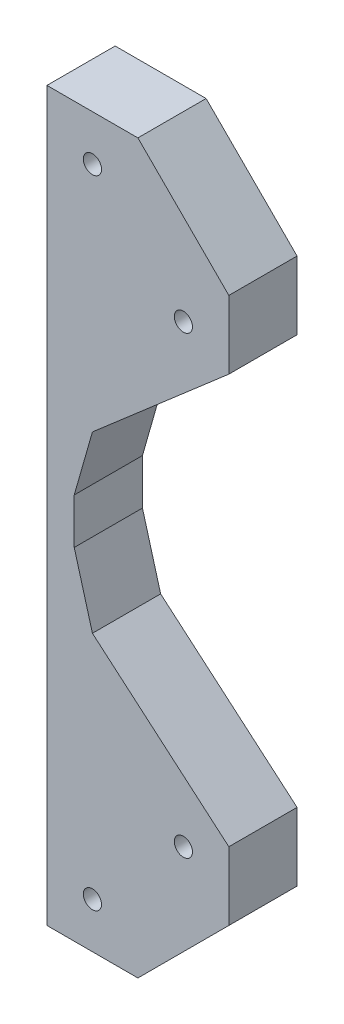
from build123d import *

# Parameters (mm, degrees)
ESBO_O1_R                = 2.000000328
ESBO_O1_R_2              = 1.999996603
ESBO_O1_R_3              = 1.999999862
RESSALTO_EXTRUS_O1_DEPTH = 15


with BuildPart() as part:
    # Esboço1 → Ressalto-extrusão1 (new body)
    with BuildSketch(Plane.XY):
        Polygon((0, 85.075276285), (19.999999553, 85.075276285), (39.999999106, 65.075280458), (39.999999106, 50.075279862), (9.999999776, 24.075279325), (6.000000052, 10.075005084), (6.000000052, 0.07499972), (9.999999776, -14.272091597), (39.999999106, -39.925275058), (39.999999106, -54.924720585), (19.999999553, -74.924720138), (0, -74.924720138), align=None)
        with Locations((9.999999776, 75.075278372)):
            Circle(ESBO_O1_R, mode=Mode.SUBTRACT)
        with Locations((29.999999329, 55.075282544)):
            Circle(ESBO_O1_R_2, mode=Mode.SUBTRACT)
        with Locations((29.999999329, -44.924718946)):
            Circle(ESBO_O1_R, mode=Mode.SUBTRACT)
        with Locations((9.999999776, -64.924719896)):
            Circle(ESBO_O1_R_3, mode=Mode.SUBTRACT)
    extrude(amount=RESSALTO_EXTRUS_O1_DEPTH)


solid = part.part
